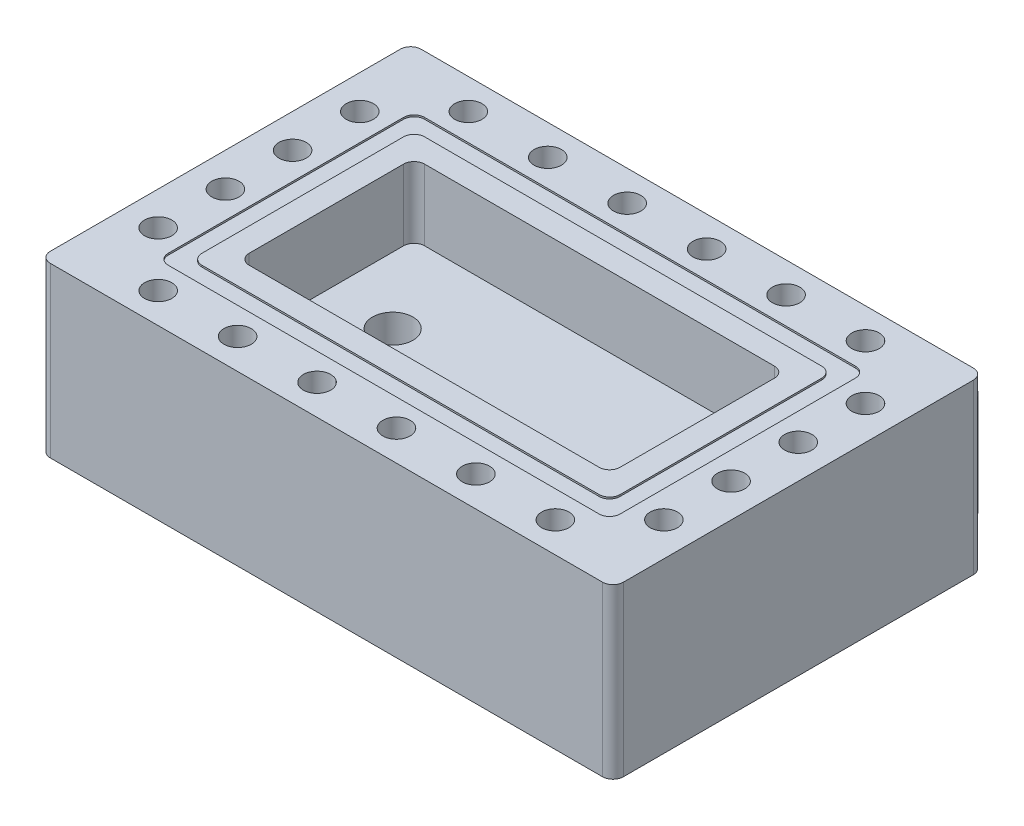
from build123d import *

# Parameters (mm, degrees)
SKETCH1_R           = 2
BOSS_EXTRUDE1_DEPTH = 25
SKETCH2_W           = 55
SKETCH2_H           = 26
CUT_EXTRUDE1_DEPTH  = 10.5
FILLET1_R           = 1.55
SKETCH3_W           = 67
SKETCH3_H           = 38
SKETCH3_W_2         = 62
SKETCH3_H_2         = 33
CUT_EXTRUDE2_DEPTH  = 0.25
FILLET2_R           = 1.55
SKETCH5_R           = 2.025
CUT_EXTRUDE4_DEPTH  = 26
SKETCH6_R           = 3
CUT_EXTRUDE5_DEPTH  = 15.5
CUT_EXTRUDE6_DEPTH  = 10


with BuildPart() as part:
    # Sketch1 → Boss-Extrude1 (new body)
    with BuildSketch(Plane(origin=(0, 0, 0), x_dir=(1, 0, 0), z_dir=(0, 1, 0))):
        with BuildLine():
            Line((80, 55), (85, 55))
            Line((85, 55), (85, 0))
            Line((85, 0), (0, 0))
            Line((0, 0), (0, 55))
            Line((0, 55), (60, 55))
            ThreePointArc((60, 55), (70, 65), (80, 55))
        make_face()
        with Locations((70, 60)):
            Circle(SKETCH1_R, mode=Mode.SUBTRACT)
    extrude(amount=BOSS_EXTRUDE1_DEPTH)

    # Sketch2 → Cut-Extrude1 (cut)
    with BuildSketch(Plane(origin=(0, 25, 0), x_dir=(1, 0, 0), z_dir=(0, 1, 0))):
        with Locations((42.5, 27.5)):
            Rectangle(SKETCH2_W, SKETCH2_H)
    extrude(amount=-CUT_EXTRUDE1_DEPTH, mode=Mode.SUBTRACT)

    # Fillet1
    fillet1_edges = [part.edges().sort_by_distance(p)[0] for p in [
        (0, 12.5, -55),
        (60, 12.5, -55),
        (80, 12.5, -55),
        (85, 12.5, -55),
        (85, 12.5, 0),
        (0, 12.5, 0),
        (15, 19.75, -14.5),
        (15, 19.75, -40.5),
        (70, 19.75, -40.5),
        (70, 19.75, -14.5),
    ]]
    fillet(fillet1_edges, radius=FILLET1_R)

    # Sketch3 → Cut-Extrude2 (cut)
    with BuildSketch(Plane(origin=(0, 25, 0), x_dir=(1, 0, 0), z_dir=(0, 1, 0))):
        with Locations((42.5, 27.5)):
            Rectangle(SKETCH3_W, SKETCH3_H)
        with Locations((42.5, 27.5)):
            Rectangle(SKETCH3_W_2, SKETCH3_H_2, mode=Mode.SUBTRACT)
    extrude(amount=-CUT_EXTRUDE2_DEPTH, mode=Mode.SUBTRACT)

    # Fillet2
    fillet2_edges = [part.edges().sort_by_distance(p)[0] for p in [
        (9, 24.875, -8.5),
        (9, 24.875, -46.5),
        (76, 24.875, -46.5),
        (76, 24.875, -8.5),
        (11.5, 24.875, -44),
        (73.5, 24.875, -44),
        (73.5, 24.875, -11),
        (11.5, 24.875, -11),
    ]]
    fillet(fillet2_edges, radius=FILLET2_R)

    # Sketch5 → Cut-Extrude4 (cut, through all)
    with BuildSketch(Plane(origin=(0, 25, 0), x_dir=(1, 0, 0), z_dir=(0, 1, 0))):
        with Locations((5, 42.45)):
            Circle(SKETCH5_R)
        with Locations((5, 12.55)):
            Circle(SKETCH5_R)
        with Locations((13.05, 4.5)):
            Circle(SKETCH5_R)
        with Locations((71.95, 4.5)):
            Circle(SKETCH5_R)
        with Locations((24.83, 4.5)):
            Circle(SKETCH5_R)
        with Locations((36.61, 4.5)):
            Circle(SKETCH5_R)
        with Locations((48.39, 4.5)):
            Circle(SKETCH5_R)
        with Locations((60.17, 4.5)):
            Circle(SKETCH5_R)
        with Locations((5, 32.483333333)):
            Circle(SKETCH5_R)
        with Locations((5, 22.516666667)):
            Circle(SKETCH5_R)
        with Locations((80, 42.45)):
            Circle(SKETCH5_R)
        with Locations((80, 12.55)):
            Circle(SKETCH5_R)
        with Locations((80, 22.516666667)):
            Circle(SKETCH5_R)
        with Locations((80, 32.483333333)):
            Circle(SKETCH5_R)
        with Locations((13.05, 50.5)):
            Circle(SKETCH5_R)
        with Locations((24.83, 50.5)):
            Circle(SKETCH5_R)
        with Locations((36.61, 50.5)):
            Circle(SKETCH5_R)
        with Locations((48.39, 50.5)):
            Circle(SKETCH5_R)
        with Locations((60.17, 50.5)):
            Circle(SKETCH5_R)
        with Locations((71.95, 50.5)):
            Circle(SKETCH5_R)
    extrude(amount=-CUT_EXTRUDE4_DEPTH, mode=Mode.SUBTRACT)

    # Sketch6 → Cut-Extrude5 (cut, through all)
    with BuildSketch(Plane(origin=(0, 14.5, 0), x_dir=(1, 0, 0), z_dir=(0, 1, 0))):
        with Locations((24.83, 27.5)):
            Circle(SKETCH6_R)
    extrude(amount=-CUT_EXTRUDE5_DEPTH, mode=Mode.SUBTRACT)

    # Sketch7 → Cut-Extrude6 (cut)
    with BuildSketch(Plane(origin=(0, 25, 0), x_dir=(1, 0, 0), z_dir=(0, 1, 0))):
        with BuildLine():
            Line((58.554476858, 55), (81.445523142, 55))
            ThreePointArc((81.445523142, 55), (80.425698015, 55.382756791), (79.909543846, 56.341991342))
            ThreePointArc((79.909543846, 56.341991342), (70, 65), (60.090456154, 56.341991342))
            ThreePointArc((60.090456154, 56.341991342), (59.574301985, 55.382756791), (58.554476858, 55))
        make_face()
    extrude(amount=-CUT_EXTRUDE6_DEPTH, mode=Mode.SUBTRACT)


solid = part.part
